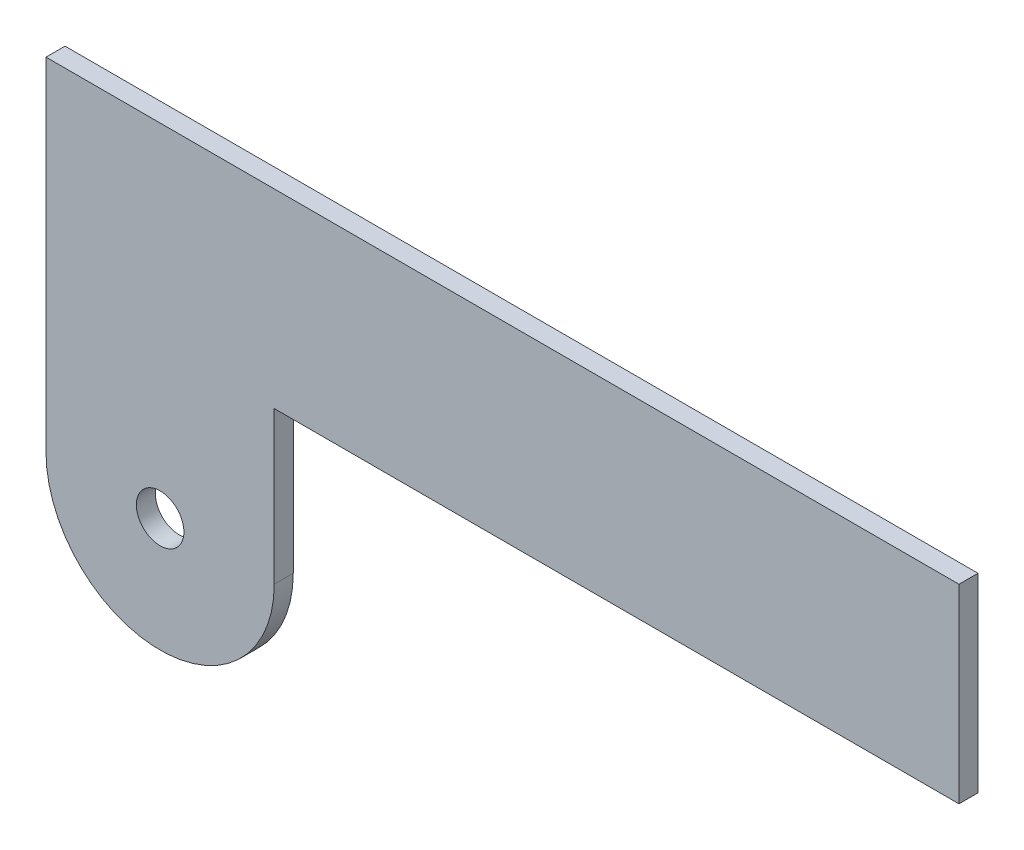
from build123d import *

# Parameters (mm, degrees)
SKETCH1_R           = 3.96875
BOSS_EXTRUDE1_DEPTH = 1.5875


with BuildPart() as part:
    # Sketch1 → Boss-Extrude1 (new body, symmetric)
    with BuildSketch(Plane.XY):
        with BuildLine():
            Line((0, 0), (0, -57.15))
            ThreePointArc((0, -57.15), (19.05, -76.2), (38.1, -57.15))
            Line((38.1, -57.15), (38.1, -31.75))
            Line((38.1, -31.75), (152.4, -31.75))
            Line((152.4, -31.75), (152.4, 0))
            Line((152.4, 0), (0, 0))
        make_face()
        with Locations((19.05, -57.15)):
            Circle(SKETCH1_R, mode=Mode.SUBTRACT)
    extrude(amount=BOSS_EXTRUDE1_DEPTH, both=True)


solid = part.part
